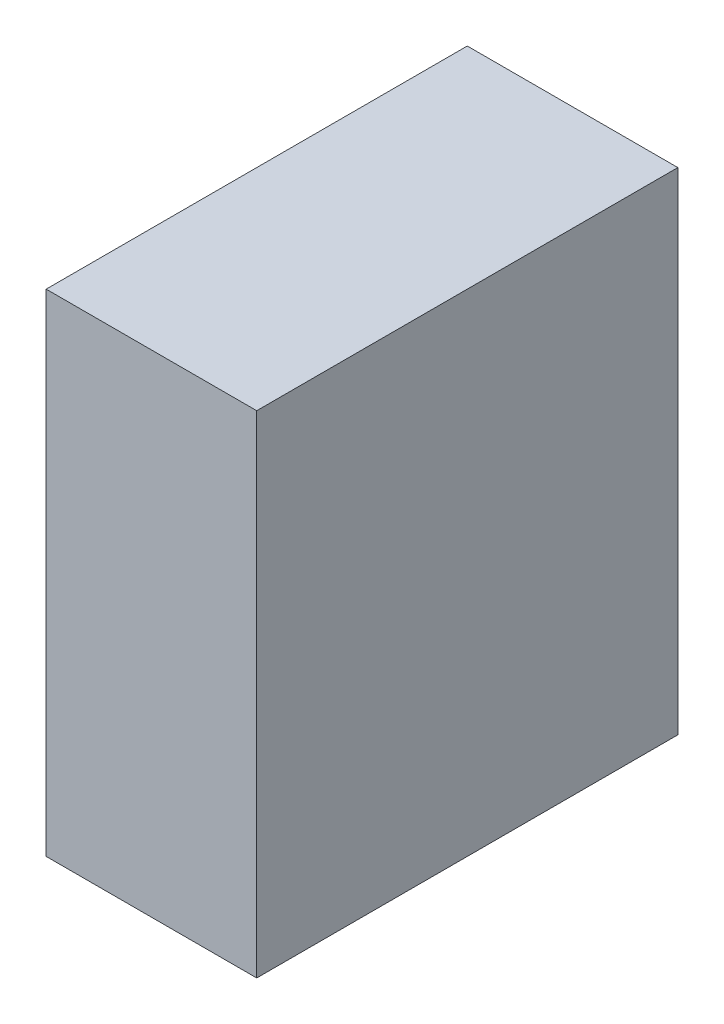
from build123d import *

# Parameters (mm, degrees)
ESQUISSE1_W        = 30
ESQUISSE1_H        = 70
BOSS_EXTRU_1_DEPTH = 60


with BuildPart() as part:
    # Esquisse1 → Boss.-Extru.1 (new body)
    with BuildSketch(Plane.XY):
        with Locations((15, 35)):
            Rectangle(ESQUISSE1_W, ESQUISSE1_H)
    extrude(amount=BOSS_EXTRU_1_DEPTH)


solid = part.part
